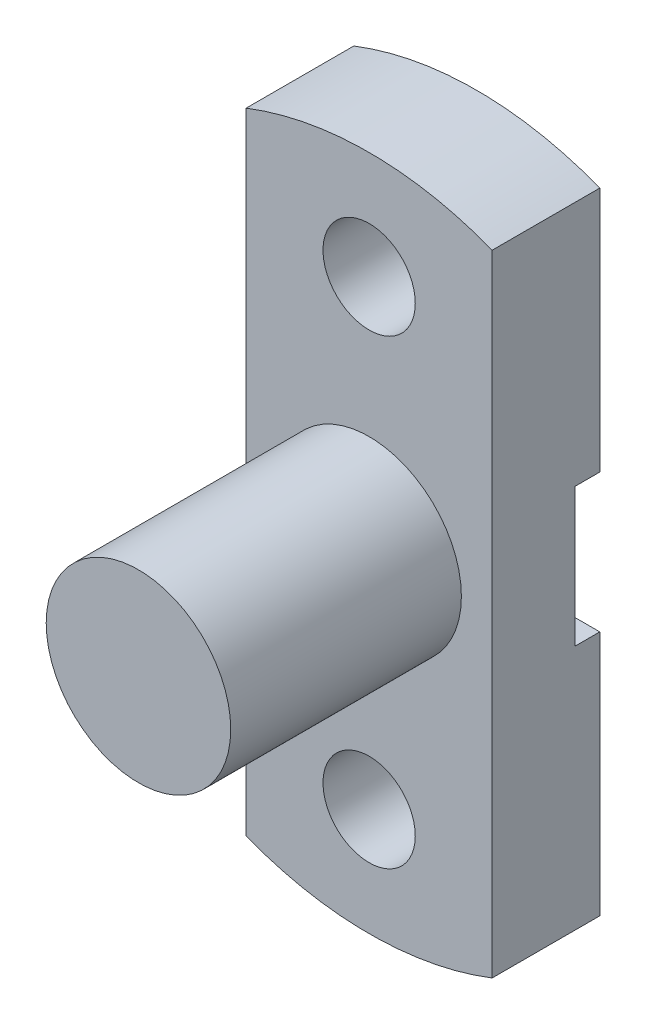
from build123d import *

# Parameters (mm, degrees)
SKETCH1_R           = 15
BOSS_EXTRUDE1_DEPTH = 35
SKETCH2_R           = 30
BOSS_EXTRUDE2_DEPTH = 75
SKETCH6_W           = 16
SKETCH6_H           = 45
CUT_EXTRUDE2_DEPTH  = 350


with BuildPart() as part:
    # Sketch1 → Boss-Extrude1 (new body)
    with BuildSketch(Plane.XY):
        with BuildLine():
            Line((-236.926286623, 264.050181211), (-236.926286623, 59.111165891))
            ThreePointArc((-236.926286623, 59.111165891), (-196.926286623, 51.580673551), (-156.926286623, 59.111165891))
            Line((-156.926286623, 59.111165891), (-156.926286623, 264.050181211))
            ThreePointArc((-156.926286623, 264.050181211), (-196.926286623, 271.580673551), (-236.926286623, 264.050181211))
        make_face()
        with Locations((-196.926286623, 236.580673551)):
            Circle(SKETCH1_R, mode=Mode.SUBTRACT)
        with Locations((-196.926286623, 86.580673551)):
            Circle(SKETCH1_R, mode=Mode.SUBTRACT)
    extrude(amount=BOSS_EXTRUDE1_DEPTH)

    # Sketch2 → Boss-Extrude2 (add)
    with BuildSketch(Plane.XY.offset(35)):
        with Locations((-196.926286623, 161.580673551)):
            Circle(SKETCH2_R)
    extrude(amount=BOSS_EXTRUDE2_DEPTH)

    # Sketch6 → Cut-Extrude2 (cut)
    with BuildSketch(Plane.ZY.offset(236.926286623)):
        with Locations((0, 161.580673551)):
            Rectangle(SKETCH6_W, SKETCH6_H)
    extrude(amount=-CUT_EXTRUDE2_DEPTH, mode=Mode.SUBTRACT)


solid = part.part
